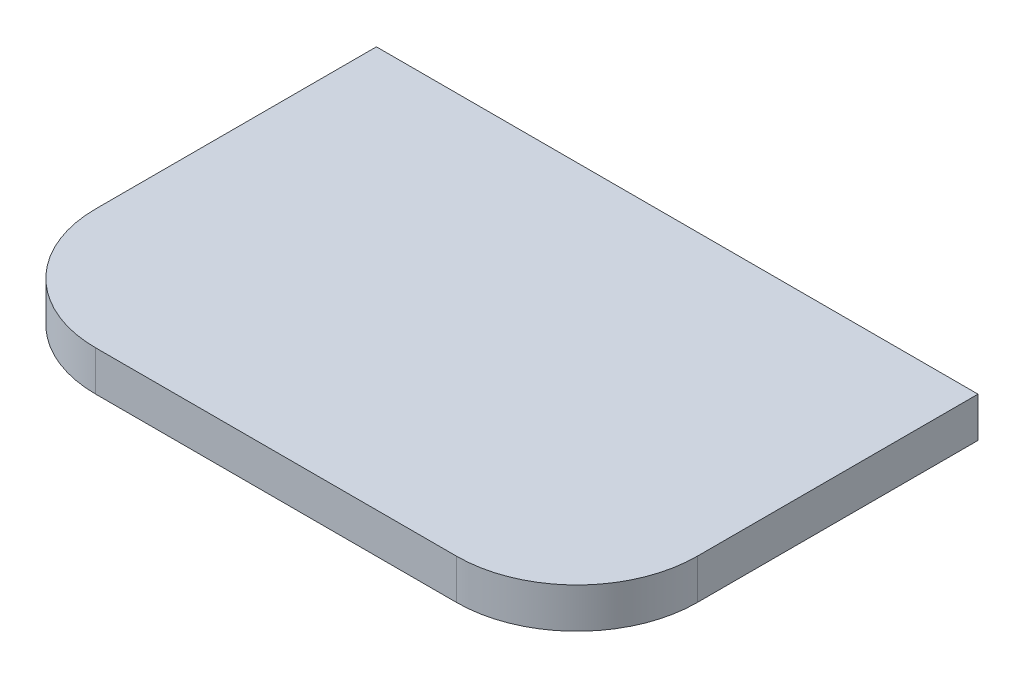
from build123d import *

# Parameters (mm, degrees)
BOSS_EXTRUDE1_DEPTH = 10


with BuildPart() as part:
    # Sketch1 → Boss-Extrude1 (new body)
    with BuildSketch(Plane(origin=(0, 0, 0), x_dir=(1, 0, 0), z_dir=(0, 1, 0))):
        with BuildLine():
            Line((-45, 0), (45, 0))
            ThreePointArc((45, 0), (66.213203436, 8.786796564), (75, 30))
            Line((75, 30), (75, 100))
            Line((75, 100), (-75, 100))
            Line((-75, 100), (-75, 30))
            ThreePointArc((-75, 30), (-66.213203436, 8.786796564), (-45, 0))
        make_face()
    extrude(amount=BOSS_EXTRUDE1_DEPTH)


solid = part.part
